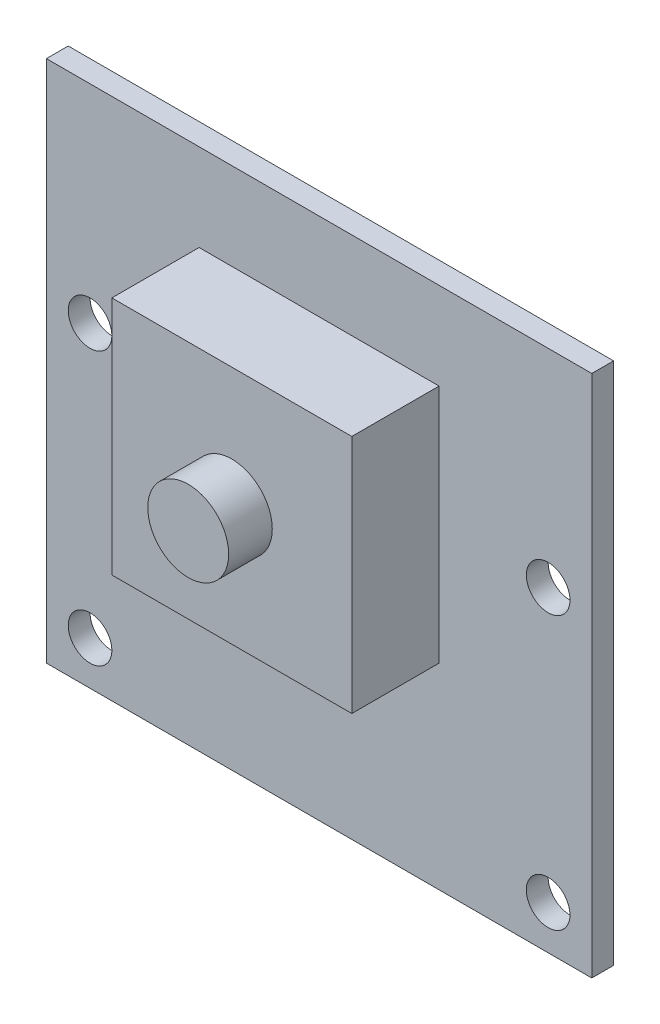
from build123d import *

# Parameters (mm, degrees)
SKETCH1_W           = 25
SKETCH1_H           = 24
SKETCH1_R           = 1
BOSS_EXTRUDE1_DEPTH = 1
SKETCH2_W           = 11
SKETCH2_H           = 11
BOSS_EXTRUDE2_DEPTH = 4
SKETCH3_R           = 1.853795749
BOSS_EXTRUDE3_DEPTH = 2


with BuildPart() as part:
    # Sketch1 → Boss-Extrude1 (new body)
    with BuildSketch(Plane.XY):
        with Locations((12.5, 12)):
            Rectangle(SKETCH1_W, SKETCH1_H)
        with Locations((2, 2)):
            Circle(SKETCH1_R, mode=Mode.SUBTRACT)
        with Locations((23, 2)):
            Circle(SKETCH1_R, mode=Mode.SUBTRACT)
        with Locations((2, 14.5)):
            Circle(SKETCH1_R, mode=Mode.SUBTRACT)
        with Locations((23, 14.5)):
            Circle(SKETCH1_R, mode=Mode.SUBTRACT)
    extrude(amount=BOSS_EXTRUDE1_DEPTH)

    # Sketch2 → Boss-Extrude2 (add)
    with BuildSketch(Plane.XY.offset(1)):
        with Locations((12.5, 14.5)):
            Rectangle(SKETCH2_W, SKETCH2_H)
    extrude(amount=BOSS_EXTRUDE2_DEPTH)

    # Sketch3 → Boss-Extrude3 (add)
    with BuildSketch(Plane.XY.offset(5)):
        with Locations((12.5, 14.5)):
            Circle(SKETCH3_R)
    extrude(amount=BOSS_EXTRUDE3_DEPTH)


solid = part.part
